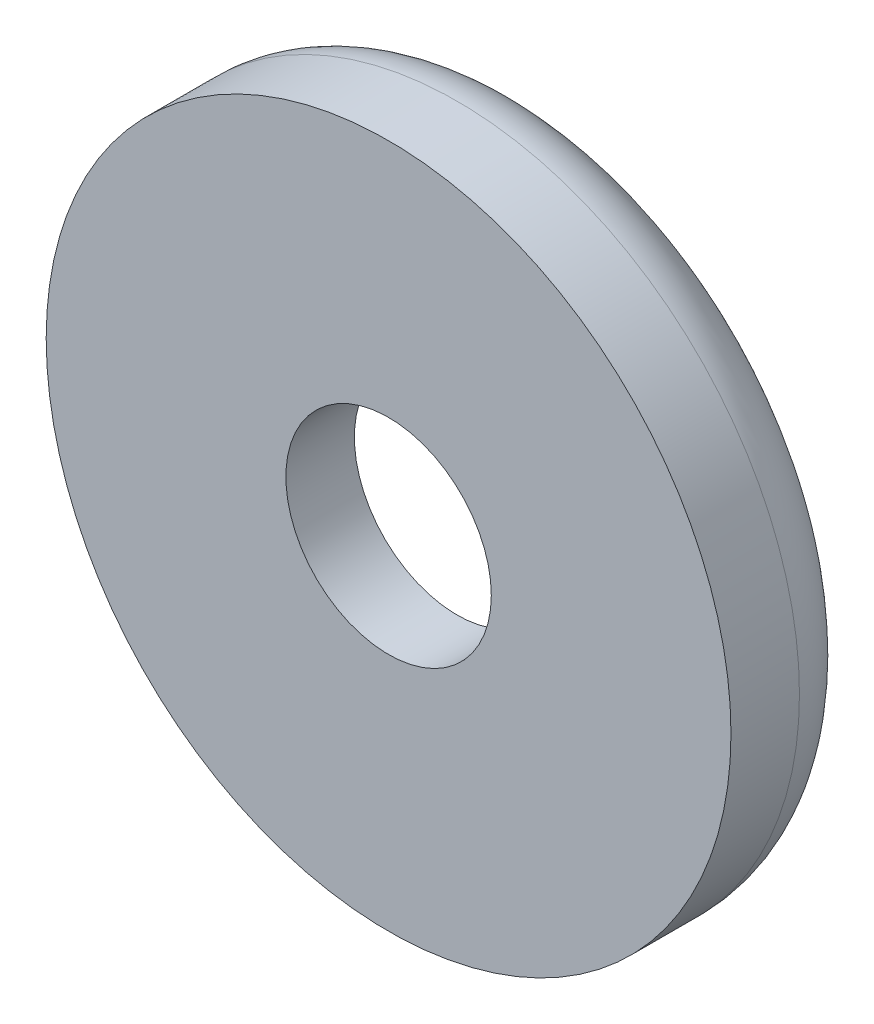
from build123d import *

# Parameters (mm, degrees)
ESQUISSE1_R             = 5
BOSS_EXTRU_1_DEPTH      = 2
ESQUISSE2_R             = 1.5
ENL_V_MAT_EXTRU_2_DEPTH = 13
ESQUISSE3_R             = 3.5
ENL_V_MAT_EXTRU_4_DEPTH = 1
CONG_1_R                = 1


with BuildPart() as part:
    # Esquisse1 → Boss.-Extru.1 (new body)
    with BuildSketch(Plane.XY):
        Circle(ESQUISSE1_R)
    extrude(amount=BOSS_EXTRU_1_DEPTH)

    # Esquisse2 → Enlèv. mat.-Extru.2 (cut)
    with BuildSketch(Plane.XY):
        Circle(ESQUISSE2_R)
    extrude(amount=ENL_V_MAT_EXTRU_2_DEPTH, mode=Mode.SUBTRACT)

    # Esquisse3 → Enlèv. mat.-Extru.4 (cut)
    with BuildSketch(Plane.XY):
        Circle(ESQUISSE3_R)
    extrude(amount=ENL_V_MAT_EXTRU_4_DEPTH, mode=Mode.SUBTRACT)

    # Congé1
    cong_1_edges = [part.edges().sort_by_distance(p)[0] for p in [
        (-5, 0, 0),
    ]]
    fillet(cong_1_edges, radius=CONG_1_R)


solid = part.part
